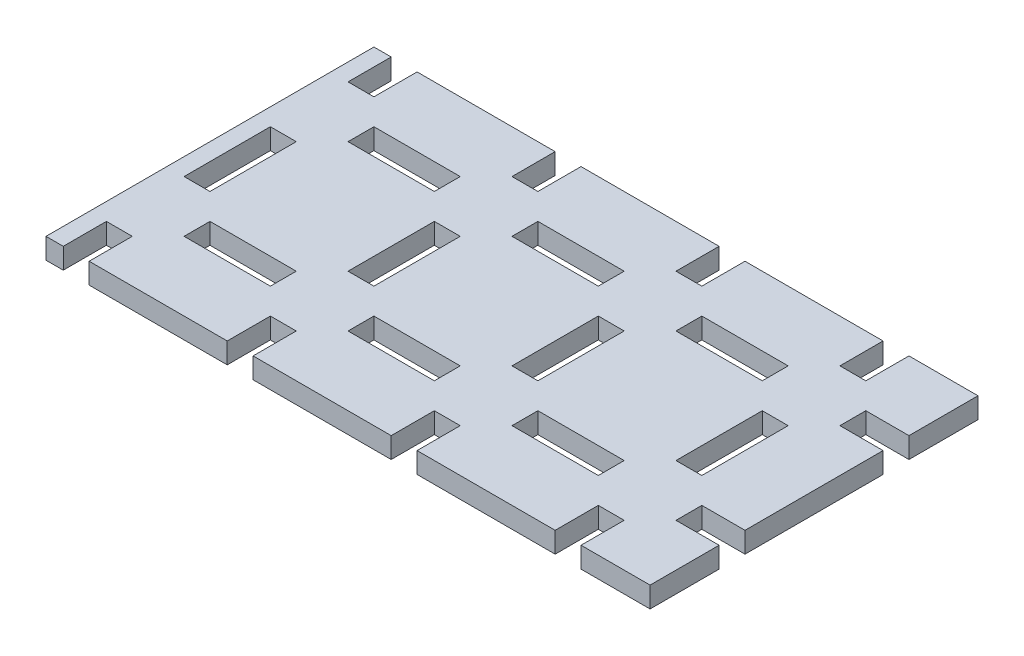
from build123d import *

# Parameters (mm, degrees)
ESQUISSE1_W             = 175
ESQUISSE1_H             = 95
BOSS_EXTRU_1_DEPTH      = 6
ESQUISSE9_W             = 25
ESQUISSE9_H             = 7.5
ESQUISSE9_W_2           = 12.5
ESQUISSE9_W_3           = 7.5
ESQUISSE9_H_2           = 12.5
ESQUISSE9_H_3           = 25
ENL_V_MAT_EXTRU_1_DEPTH = 6000


with BuildPart() as part:
    # Esquisse1 → Boss.-Extru.1 (new body)
    with BuildSketch(Plane(origin=(0, 0, 0), x_dir=(1, 0, 0), z_dir=(0, 1, 0))):
        with Locations((-87.5, -47.5)):
            Rectangle(ESQUISSE1_W, ESQUISSE1_H)
    extrude(amount=BOSS_EXTRU_1_DEPTH)

    # Esquisse9 → Enlèv. mat.-Extru.1 (cut)
    with BuildSketch(Plane(origin=(0, 6, 0), x_dir=(1, 0, 0), z_dir=(0, 1, 0))):
        with Locations((-142.5, -23.75)):
            Rectangle(ESQUISSE9_W, ESQUISSE9_H)
        with Locations((-142.5, -71.25)):
            Rectangle(ESQUISSE9_W, ESQUISSE9_H)
        with Locations((-95, -71.25)):
            Rectangle(ESQUISSE9_W, ESQUISSE9_H)
        with Locations((-95, -23.75)):
            Rectangle(ESQUISSE9_W, ESQUISSE9_H)
        with Locations((-47.5, -23.75)):
            Rectangle(ESQUISSE9_W, ESQUISSE9_H)
        with Locations((-6.25, -23.75)):
            Rectangle(ESQUISSE9_W_2, ESQUISSE9_H)
        with Locations((-47.5, -71.25)):
            Rectangle(ESQUISSE9_W, ESQUISSE9_H)
        with Locations((-6.25, -71.25)):
            Rectangle(ESQUISSE9_W_2, ESQUISSE9_H)
        with Locations((-166.25, -88.75)):
            Rectangle(ESQUISSE9_W_3, ESQUISSE9_H_2)
        with Locations((-166.25, -47.5)):
            Rectangle(ESQUISSE9_W_3, ESQUISSE9_H_3)
        with Locations((-166.25, -6.25)):
            Rectangle(ESQUISSE9_W_3, ESQUISSE9_H_2)
        with Locations((-118.75, -88.75)):
            Rectangle(ESQUISSE9_W_3, ESQUISSE9_H_2)
        with Locations((-71.25, -88.75)):
            Rectangle(ESQUISSE9_W_3, ESQUISSE9_H_2)
        with Locations((-23.75, -88.75)):
            Rectangle(ESQUISSE9_W_3, ESQUISSE9_H_2)
        with Locations((-118.75, -47.5)):
            Rectangle(ESQUISSE9_W_3, ESQUISSE9_H_3)
        with Locations((-71.25, -47.5)):
            Rectangle(ESQUISSE9_W_3, ESQUISSE9_H_3)
        with Locations((-23.75, -47.5)):
            Rectangle(ESQUISSE9_W_3, ESQUISSE9_H_3)
        with Locations((-118.75, -6.25)):
            Rectangle(ESQUISSE9_W_3, ESQUISSE9_H_2)
        with Locations((-71.25, -6.25)):
            Rectangle(ESQUISSE9_W_3, ESQUISSE9_H_2)
        with Locations((-23.75, -6.25)):
            Rectangle(ESQUISSE9_W_3, ESQUISSE9_H_2)
    extrude(amount=-ENL_V_MAT_EXTRU_1_DEPTH, mode=Mode.SUBTRACT)


solid = part.part
